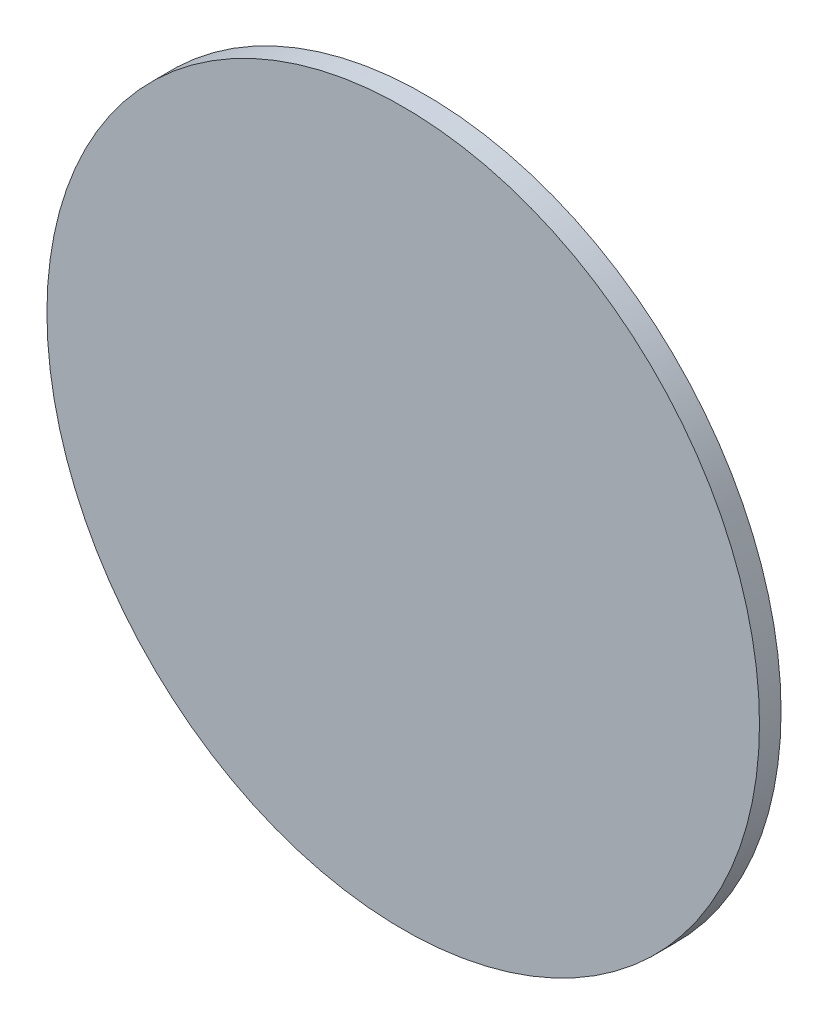
from build123d import *

# Parameters (mm, degrees)
SKETCH1_R           = 8.382
BOSS_EXTRUDE1_DEPTH = 0.508


with BuildPart() as part:
    # Sketch1 → Boss-Extrude1 (new body)
    with BuildSketch(Plane.XY):
        Circle(SKETCH1_R)
    extrude(amount=BOSS_EXTRUDE1_DEPTH)


solid = part.part
